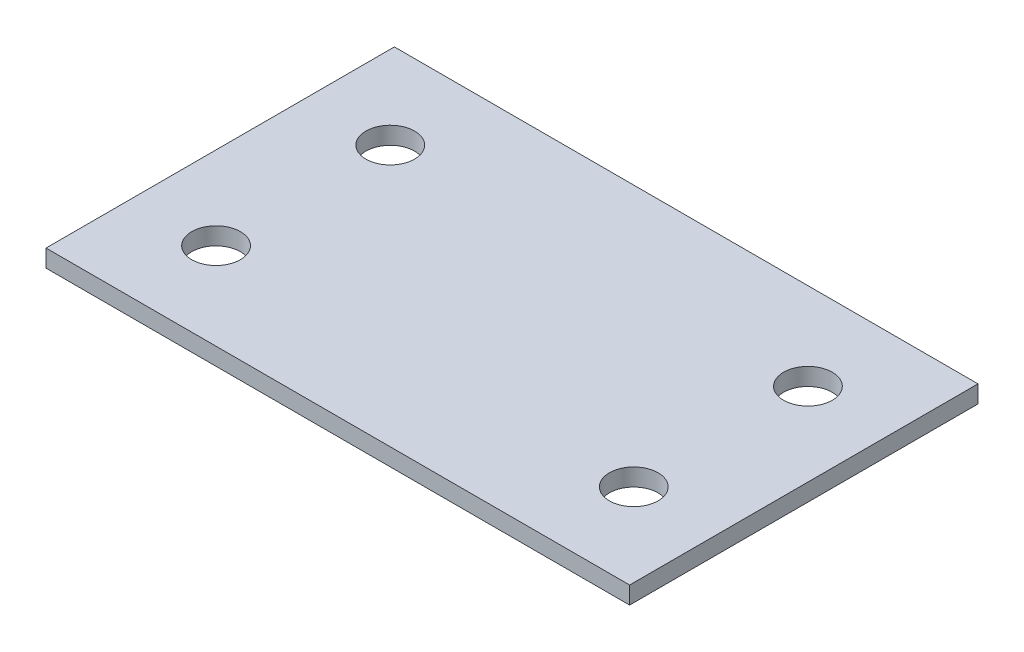
from build123d import *

# Parameters (mm, degrees)
BOSS_EXTRUDE1_DEPTH = 20
SKETCH6_R           = 1.397
CUT_EXTRUDE1_DEPTH  = 1
SKETCH7_W           = 2.16646989
SKETCH7_H           = 20
BOSS_EXTRUDE2_DEPTH = 1


with BuildPart() as part:
    # Sketch1 → Boss-Extrude1 (new body)
    with BuildSketch(Plane.XY):
        Polygon((0, 0), (2.596030114, 0), (29.171217845, 0), (29.171217845, 1), (26.575187731, 1), (0, 1), align=None)
    extrude(amount=BOSS_EXTRUDE1_DEPTH)

    # Sketch6 → Cut-Extrude1 (cut)
    with BuildSketch(Plane(origin=(0, 1, 0), x_dir=(1, 0, 0), z_dir=(0, 1, 0))):
        with Locations((26.575187731, -15.000000033)):
            Circle(SKETCH6_R)
        with Locations((2.596030114, -15.000000033)):
            Circle(SKETCH6_R)
        with Locations((2.596030114, -4.999999967)):
            Circle(SKETCH6_R)
        with Locations((26.575187731, -4.999999967)):
            Circle(SKETCH6_R)
    extrude(amount=-CUT_EXTRUDE1_DEPTH, mode=Mode.SUBTRACT)

    # Sketch7 → Boss-Extrude2 (add)
    with BuildSketch(Plane(origin=(0, 1, 0), x_dir=(1, 0, 0), z_dir=(0, 1, 0))):
        with Locations((30.25445279, -10)):
            Rectangle(SKETCH7_W, SKETCH7_H)
        with Locations((-1.083234945, -10)):
            Rectangle(SKETCH7_W, SKETCH7_H)
    extrude(amount=-BOSS_EXTRUDE2_DEPTH)


solid = part.part
